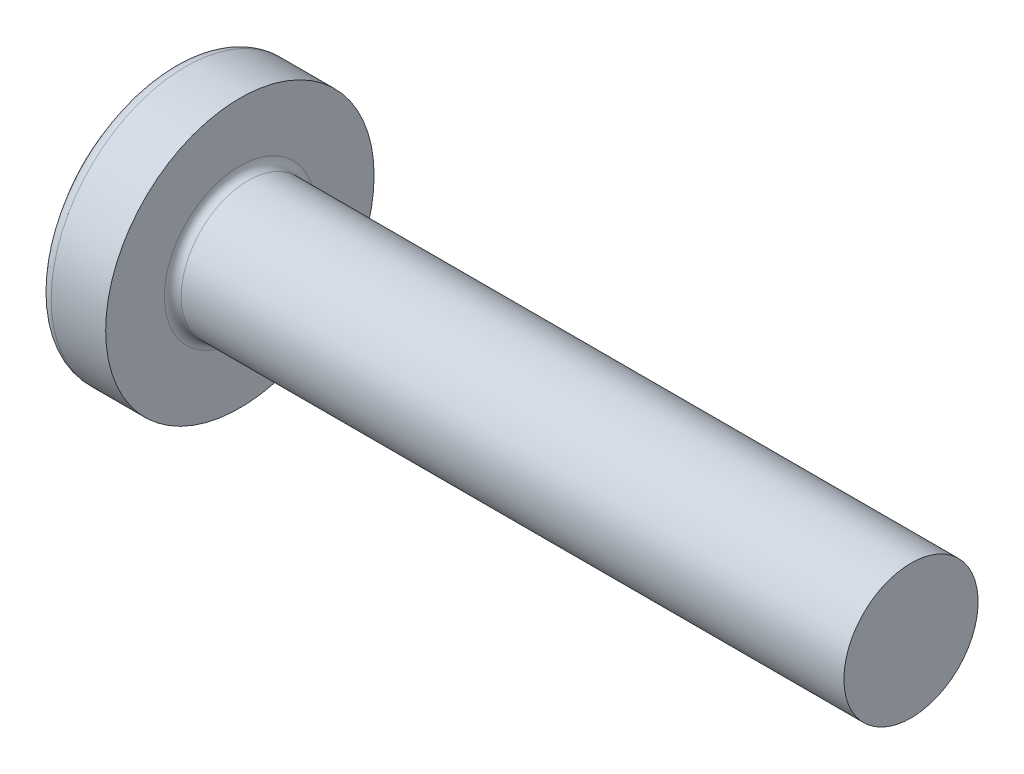
from build123d import *

# Parameters (mm, degrees)
FILLET1_R    = 0.1
SKETCH3_W    = 0.48
SKETCH3_H    = 1.6
SKETCH4_W    = 0.48
SKETCH4_H    = 0.702553256
RECPAT_COUNT = 2
RECPAT_ANGLE = 90


with BuildPart() as part:
    # BodySke → Base-Revolve (revolve)
    with BuildSketch(Plane.XY):
        with BuildLine():
            Line((1.3, 0.8), (1.3, 1.6))
            Line((1.3, 1.6), (0.650675799, 1.6))
            ThreePointArc((0.650675799, 1.6), (0.585036553, 1.584875829), (0.532633829, 1.542553191))
            ThreePointArc((0.532633829, 1.542553191), (0.136907172, 0.815960959), (0, 0))
            Line((0, 0), (9.3, 0))
            Line((9.3, 0), (9.3, 0.8))
            Line((9.3, 0.8), (1.3, 0.8))
        make_face()
    revolve(axis=Axis((-25.4, 0, 0), (1, 0, 0)))

    # Fillet1
    fillet1_edges = [part.edges().sort_by_distance(p)[0] for p in [
        (1.3, -0.8, 0),
    ]]
    fillet(fillet1_edges, radius=FILLET1_R)

    # Sketch3 → Recess section 0
    with BuildSketch(Plane(origin=(0, 0, 0), x_dir=(0, 0, -1), z_dir=(1, 0, 0))):
        Rectangle(SKETCH3_W, SKETCH3_H)
    # Sketch4 → Recess section 1
    with BuildSketch(Plane(origin=(0.9, 0, 0), x_dir=(0, 0, -1), z_dir=(1, 0, 0))):
        Rectangle(SKETCH4_W, SKETCH4_H)
    recess = loft(mode=Mode.SUBTRACT)

    # RecPat: Recess ×2 about axis
    recpat_axis = Axis((0, 0, 0), (1, 0, 0))
    for i in range(1, RECPAT_COUNT):
        add(recess.rotate(recpat_axis, i * RECPAT_ANGLE / (RECPAT_COUNT - 1)), mode=Mode.SUBTRACT)

    # RecCorSke → RecessCore (revolve, cut)
    with BuildSketch(Plane.XY):
        Polygon((0, 0), (0, 0.418434131), (0.9, 0.3555), (1.015508952, 0), align=None)
    revolve(axis=Axis((-3.175, 0, 0), (1, 0, 0)), mode=Mode.SUBTRACT)


solid = part.part
